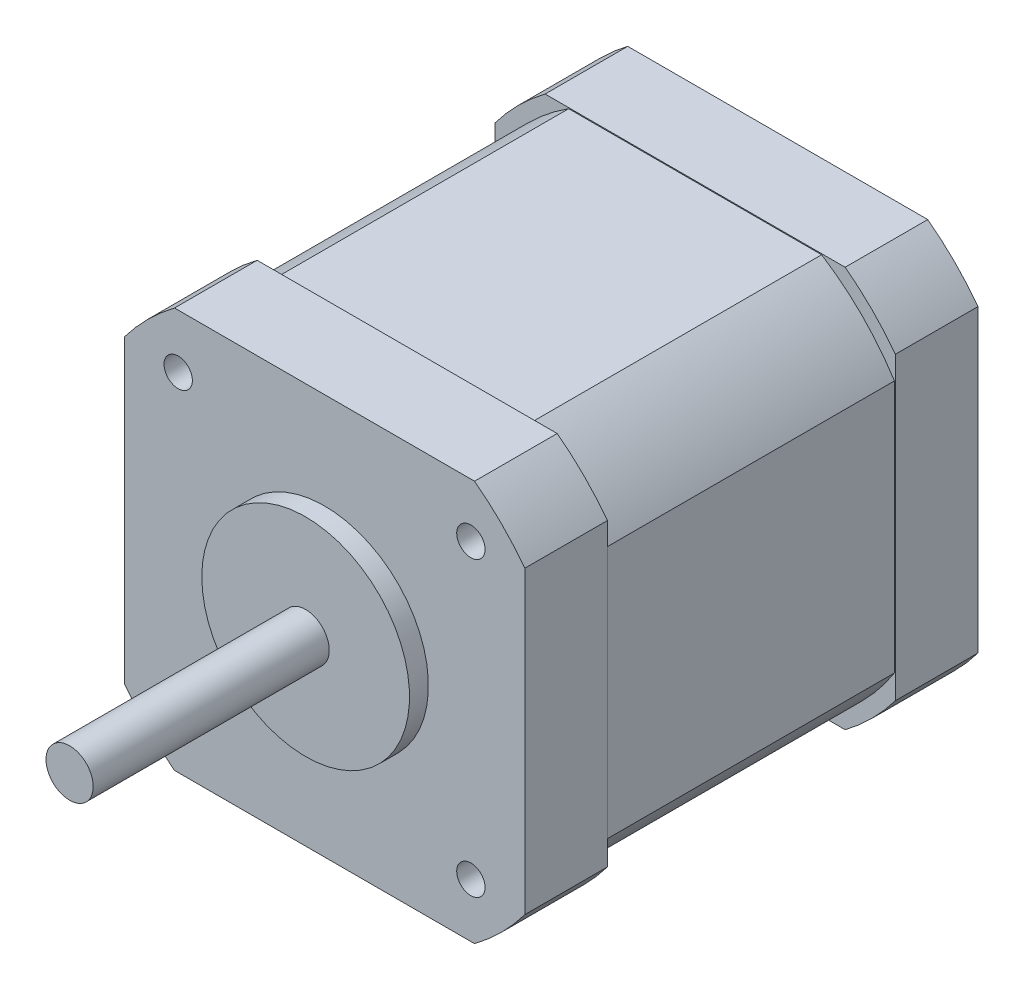
from build123d import *

# Parameters (mm, degrees)
SKETCH1_R                       = 2.5
BOSS_EXTRUDE1_DEPTH             = 27
SKETCH2_R                       = 11
BOSS_EXTRUDE2_DEPTH             = 2
SKETCH3_W                       = 42.418
SKETCH3_H                       = 42.418
BOSS_EXTRUDE3_DEPTH             = 48
CUT_EXTRUDE1_DEPTH              = 76
M3X0_5_TAPPED_HOLE1_D           = 2.5
M3X0_5_TAPPED_HOLE1_DEPTH       = 7.5
M3X0_5_TAPPED_HOLE1_CBORE_D     = 3
M3X0_5_TAPPED_HOLE1_CBORE_DEPTH = 6
M3X0_5_TAPPED_HOLE1_TIP         = 0.751075774
CUT_EXTRUDE3_DEPTH              = 15.25
CUT_EXTRUDE3_DEPTH_BACK         = 15.25
SKETCH9_W                       = 16
SKETCH9_H                       = 4.5
BOSS_EXTRUDE4_DEPTH             = 4.75


with BuildPart() as part:
    # Sketch1 → Boss-Extrude1 (new body)
    with BuildSketch(Plane.XY):
        Circle(SKETCH1_R)
    extrude(amount=BOSS_EXTRUDE1_DEPTH)

    # Sketch2 → Boss-Extrude2 (add)
    with BuildSketch(Plane(origin=(0, 0, 0), x_dir=(-1, 0, 0), z_dir=(0, 0, -1))):
        Circle(SKETCH2_R)
    extrude(amount=-BOSS_EXTRUDE2_DEPTH)

    # Sketch3 → Boss-Extrude3 (add)
    with BuildSketch(Plane(origin=(0, 0, 0), x_dir=(-1, 0, 0), z_dir=(0, 0, -1))):
        Rectangle(SKETCH3_W, SKETCH3_H)
    extrude(amount=BOSS_EXTRUDE3_DEPTH)

    # Sketch4 → Cut-Extrude1 (cut, through all)
    with BuildSketch(Plane(origin=(0, 0, -48), x_dir=(-1, 0, 0), z_dir=(0, 0, -1))):
        with BuildLine():
            Line((-21.209, -15.887992919), (-21.209, -21.209))
            Line((-21.209, -21.209), (-15.887992919, -21.209))
            ThreePointArc((-15.887992919, -21.209), (-18.738329701, -18.738329701), (-21.209, -15.887992919))
        make_face()
        with BuildLine():
            Line((15.887992919, -21.209), (21.209, -21.209))
            Line((21.209, -21.209), (21.209, -15.887992919))
            ThreePointArc((21.209, -15.887992919), (18.738329701, -18.738329701), (15.887992919, -21.209))
        make_face()
        with BuildLine():
            Line((21.209, 15.887992919), (21.209, 21.209))
            Line((21.209, 21.209), (15.887992919, 21.209))
            ThreePointArc((15.887992919, 21.209), (18.738329701, 18.738329701), (21.209, 15.887992919))
        make_face()
        with BuildLine():
            Line((-15.887992919, 21.209), (-21.209, 21.209))
            Line((-21.209, 21.209), (-21.209, 15.887992919))
            ThreePointArc((-21.209, 15.887992919), (-18.738329701, 18.738329701), (-15.887992919, 21.209))
        make_face()
    extrude(amount=-CUT_EXTRUDE1_DEPTH, mode=Mode.SUBTRACT)

    # M3x0.5 Tapped Hole1
    with Locations(Plane.XY):
        with Locations((-15.5, 15.5), (-15.5, -15.5), (15.5, -15.5), (15.5, 15.5)):
            CounterBoreHole(M3X0_5_TAPPED_HOLE1_D / 2, M3X0_5_TAPPED_HOLE1_CBORE_D / 2, M3X0_5_TAPPED_HOLE1_CBORE_DEPTH, depth=M3X0_5_TAPPED_HOLE1_DEPTH)
            with Locations((0, 0, -(M3X0_5_TAPPED_HOLE1_DEPTH + M3X0_5_TAPPED_HOLE1_TIP / 2))):  # 118° drill point
                Cone(0, M3X0_5_TAPPED_HOLE1_D / 2, M3X0_5_TAPPED_HOLE1_TIP, mode=Mode.SUBTRACT)

    # Sketch8 → Cut-Extrude3 (cut, two sides)
    with BuildSketch(Plane.XY.offset(-24)) as cut_extrude3_sk:
        with BuildLine():
            Line((15.887992919, 21.209), (-15.887992919, 21.209))
            ThreePointArc((-15.887992919, 21.209), (-18.738329701, 18.738329701), (-21.209, 15.887992919))
            Line((-21.209, 15.887992919), (-21.209, -15.887992919))
            ThreePointArc((-21.209, -15.887992919), (-18.738329701, -18.738329701), (-15.887992919, -21.209))
            Line((-15.887992919, -21.209), (15.887992919, -21.209))
            ThreePointArc((15.887992919, -21.209), (18.738329701, -18.738329701), (21.209, -15.887992919))
            Line((21.209, -15.887992919), (21.209, 15.887992919))
            ThreePointArc((21.209, 15.887992919), (18.738329701, 18.738329701), (15.887992919, 21.209))
        make_face()
        with BuildLine():
            Line((-13.394406258, 21.109), (13.394406258, 21.109))
            ThreePointArc((13.394406258, 21.109), (17.67766953, 17.67766953), (21.109, 13.394406258))
            Line((21.109, 13.394406258), (21.109, -13.394406258))
            ThreePointArc((21.109, -13.394406258), (17.67766953, -17.67766953), (13.394406258, -21.109))
            Line((13.394406258, -21.109), (-13.394406258, -21.109))
            ThreePointArc((-13.394406258, -21.109), (-17.67766953, -17.67766953), (-21.109, -13.394406258))
            Line((-21.109, -13.394406258), (-21.109, 13.394406258))
            ThreePointArc((-21.109, 13.394406258), (-17.67766953, 17.67766953), (-13.394406258, 21.109))
        make_face(mode=Mode.SUBTRACT)
    extrude(amount=CUT_EXTRUDE3_DEPTH, mode=Mode.SUBTRACT)
    extrude(cut_extrude3_sk.sketch, amount=-CUT_EXTRUDE3_DEPTH_BACK, mode=Mode.SUBTRACT)

    # Sketch9 → Boss-Extrude4 (add)
    with BuildSketch(Plane.XZ.offset(21.209)):
        with Locations((0, -45.75)):
            Rectangle(SKETCH9_W, SKETCH9_H)
    extrude(amount=BOSS_EXTRUDE4_DEPTH)


solid = part.part
